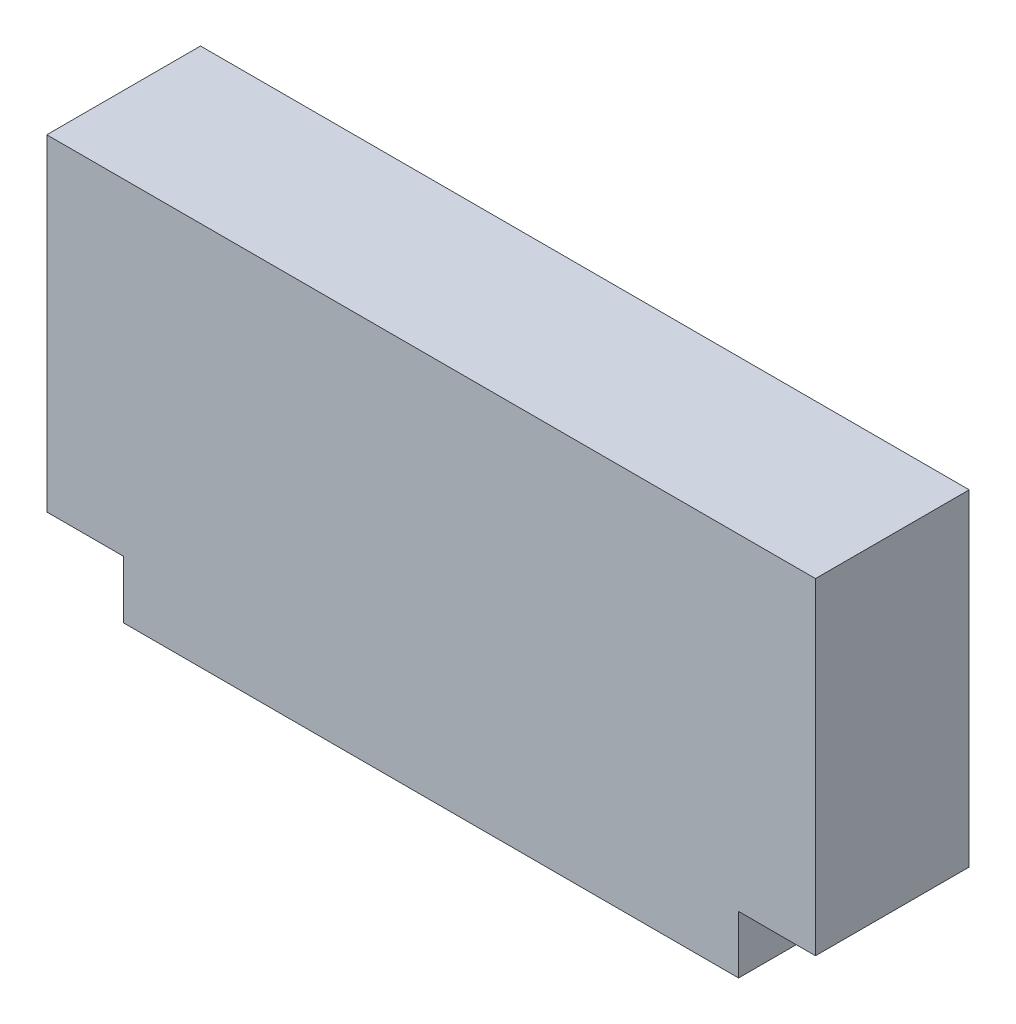
from build123d import *

# Parameters (mm, degrees)
EXTRUDE_1_DEPTH = 8


with BuildPart() as part:
    # Эскиз1 → Бобышка-Вытянуть1 (new body)
    with BuildSketch(Plane.XY):
        Polygon((-16, 0), (16, 0), (16, 3), (20, 3), (20, 20), (-20, 20), (-20, 3), (-16, 3), align=None)
    extrude(amount=EXTRUDE_1_DEPTH)


solid = part.part
